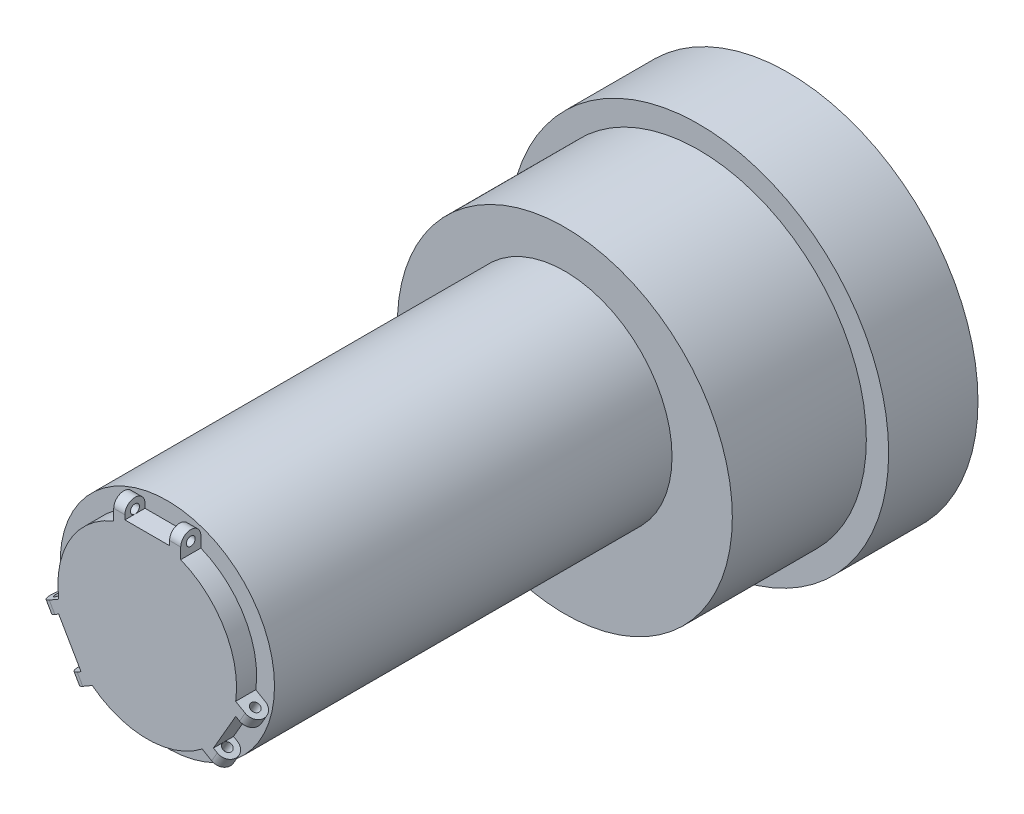
from build123d import *

# Parameters (mm, degrees)
SKETCH_1_R          = 42.5
EXTRUDE_1_DEPTH     = 20
SKETCH_2_R          = 37.5
EXTRUDE_2_DEPTH     = 30
SKETCH_3_R          = 24
EXTRUDE_3_DEPTH     = 89
SKETCH_5_R          = 20
EXTRUDE_4_DEPTH     = 4.5
SKETCH_7_W          = 15
SKETCH_7_H          = 4.5
EXTRUDE_5_DEPTH     = 10
SKETCH_8_W          = 4.5
SKETCH_8_H          = 15
EXTRUDE_6_DEPTH     = 10
SKETCH_9_W          = 4.5
SKETCH_9_H          = 15
EXTRUDE_7_DEPTH     = 10
EXTRUDE_8_DEPTH     = 15
EXTRUDE_9_DEPTH     = 15
EXTRUDE_10_DEPTH    = 15
SKETCH_13_R         = 1
CUT_EXTRUDE_1_DEPTH = 51
SKETCH_14_R         = 1
CUT_EXTRUDE_2_DEPTH = 62.225952642
SKETCH_15_R         = 1
CUT_EXTRUDE_3_DEPTH = 70.88620668
SKETCH_18_W         = 4.5
SKETCH_18_H         = 10
CUT_EXTRUDE_4_DEPTH = 3.25
SKETCH_19_W         = 4.5
SKETCH_19_H         = 10
CUT_EXTRUDE_5_DEPTH = 3.25
SKETCH_20_W         = 10
SKETCH_20_H         = 4.5
CUT_EXTRUDE_6_DEPTH = 3.25


with BuildPart() as part:
    # ｽｹｯﾁ1 → ﾎﾞｽ - 押し出し1 (new body)
    with BuildSketch(Plane.XY):
        Circle(SKETCH_1_R)
    extrude(amount=EXTRUDE_1_DEPTH)

    # ｽｹｯﾁ2 → ﾎﾞｽ - 押し出し2 (add)
    with BuildSketch(Plane.XY.offset(20)):
        Circle(SKETCH_2_R)
    extrude(amount=EXTRUDE_2_DEPTH)

    # ｽｹｯﾁ3 → ﾎﾞｽ - 押し出し3 (add)
    with BuildSketch(Plane.XY.offset(50)):
        with Locations((0, 5)):
            Circle(SKETCH_3_R)
    extrude(amount=EXTRUDE_3_DEPTH)

    # ｽｹｯﾁ5 → ﾎﾞｽ - 押し出し4 (add)
    with BuildSketch(Plane.XY.offset(139)):
        with Locations((0, 5)):
            Circle(SKETCH_5_R)
    extrude(amount=EXTRUDE_4_DEPTH)

    # ｽｹｯﾁ7 → ﾎﾞｽ - 押し出し5 (add)
    with BuildSketch(Plane(origin=(0, 25, 0), x_dir=(1, 0, 0), z_dir=(0, 1, 0))):
        with Locations((0, -141.25)):
            Rectangle(SKETCH_7_W, SKETCH_7_H)
    extrude(amount=-EXTRUDE_5_DEPTH)

    # ｽｹｯﾁ8 → ﾎﾞｽ - 押し出し6 (add)
    with BuildSketch(Plane(origin=(-15.155444566, -8.75, 0), x_dir=(0, 0, 1), z_dir=(-0.866025404, -0.5, 0))):
        with Locations((141.25, 4.330127019)):
            Rectangle(SKETCH_8_W, SKETCH_8_H)
    extrude(amount=-EXTRUDE_6_DEPTH)

    # ｽｹｯﾁ9 → ﾎﾞｽ - 押し出し7 (add)
    with BuildSketch(Plane(origin=(15.155444566, -8.75, 0), x_dir=(0, 0, -1), z_dir=(0.866025404, -0.5, 0))):
        with Locations((-141.25, 4.330127019)):
            Rectangle(SKETCH_9_W, SKETCH_9_H)
    extrude(amount=-EXTRUDE_7_DEPTH)

    # ｽｹｯﾁ10 → ﾎﾞｽ - 押し出し8 (add)
    with BuildSketch(Plane(origin=(5.915063509, 10.245190528, 0), x_dir=(0.866025404, -0.5, 0), z_dir=(0.5, 0.866025404, 0))):
        with BuildLine():
            Line((17.5, -143.5), (18.5, -143.5))
            ThreePointArc((18.5, -143.5), (20.75, -141.25), (18.5, -139))
            Line((18.5, -139), (17.5, -139))
            Line((17.5, -139), (17.5, -143.5))
        make_face()
    extrude(amount=-EXTRUDE_8_DEPTH)

    # ｽｹｯﾁ11 → ﾎﾞｽ - 押し出し9 (add)
    with BuildSketch(Plane.ZY.offset(7.5)):
        with BuildLine():
            Line((139, 25), (143.5, 25))
            Line((143.5, 25), (143.5, 26))
            ThreePointArc((143.5, 26), (141.25, 28.25), (139, 26))
            Line((139, 26), (139, 25))
        make_face()
    extrude(amount=-EXTRUDE_9_DEPTH)

    # ｽｹｯﾁ12 → ﾎﾞｽ - 押し出し10 (add)
    with BuildSketch(Plane(origin=(1.584936491, -2.745190528, 0), x_dir=(0.866025404, 0.5, 0), z_dir=(0.5, -0.866025404, 0))):
        with BuildLine():
            Line((-17.5, 139), (-17.5, 143.5))
            Line((-17.5, 143.5), (-18.5, 143.5))
            ThreePointArc((-18.5, 143.5), (-20.75, 141.25), (-18.5, 139))
            Line((-18.5, 139), (-17.5, 139))
        make_face()
    extrude(amount=-EXTRUDE_10_DEPTH)

    # ｽｹｯﾁ13 → ｶｯﾄ - 押し出し1 (cut, through all)
    with BuildSketch(Plane.ZY.offset(7.5)):
        with Locations((141.25, 26)):
            Circle(SKETCH_13_R)
    extrude(amount=-CUT_EXTRUDE_1_DEPTH, mode=Mode.SUBTRACT)

    # ｽｹｯﾁ14 → ｶｯﾄ - 押し出し2 (cut, through all)
    with BuildSketch(Plane(origin=(1.584936491, -2.745190528, 0), x_dir=(-0.866025404, -0.5, 0), z_dir=(0.5, -0.866025404, 0))):
        with Locations((18.5, -141.25)):
            Circle(SKETCH_14_R)
    extrude(amount=-CUT_EXTRUDE_2_DEPTH, mode=Mode.SUBTRACT)

    # ｽｹｯﾁ15 → ｶｯﾄ - 押し出し3 (cut, through all)
    with BuildSketch(Plane(origin=(5.915063509, 10.245190528, 0), x_dir=(0.866025404, -0.5, 0), z_dir=(0.5, 0.866025404, 0))):
        with Locations((18.5, -141.25)):
            Circle(SKETCH_15_R)
    extrude(amount=-CUT_EXTRUDE_3_DEPTH, mode=Mode.SUBTRACT)

    # ｽｹｯﾁ18 → ｶｯﾄ - 押し出し4 (cut)
    with BuildSketch(Plane(origin=(-17.970027129, -10.375, 0), x_dir=(0, 0, 1), z_dir=(-0.866025404, -0.5, 0))):
        with Locations((141.25, 4.330127019)):
            Rectangle(SKETCH_18_W, SKETCH_18_H)
    extrude(amount=-CUT_EXTRUDE_4_DEPTH, mode=Mode.SUBTRACT)

    # ｽｹｯﾁ19 → ｶｯﾄ - 押し出し5 (cut)
    with BuildSketch(Plane(origin=(17.970027129, -10.375, 0), x_dir=(0, 0, -1), z_dir=(0.866025404, -0.5, 0))):
        with Locations((-141.25, 4.330127019)):
            Rectangle(SKETCH_19_W, SKETCH_19_H)
    extrude(amount=-CUT_EXTRUDE_5_DEPTH, mode=Mode.SUBTRACT)

    # ｽｹｯﾁ20 → ｶｯﾄ - 押し出し6 (cut)
    with BuildSketch(Plane(origin=(0, 28.25, 0), x_dir=(1, 0, 0), z_dir=(0, 1, 0))):
        with Locations((0, -141.25)):
            Rectangle(SKETCH_20_W, SKETCH_20_H)
    extrude(amount=-CUT_EXTRUDE_6_DEPTH, mode=Mode.SUBTRACT)


solid = part.part
